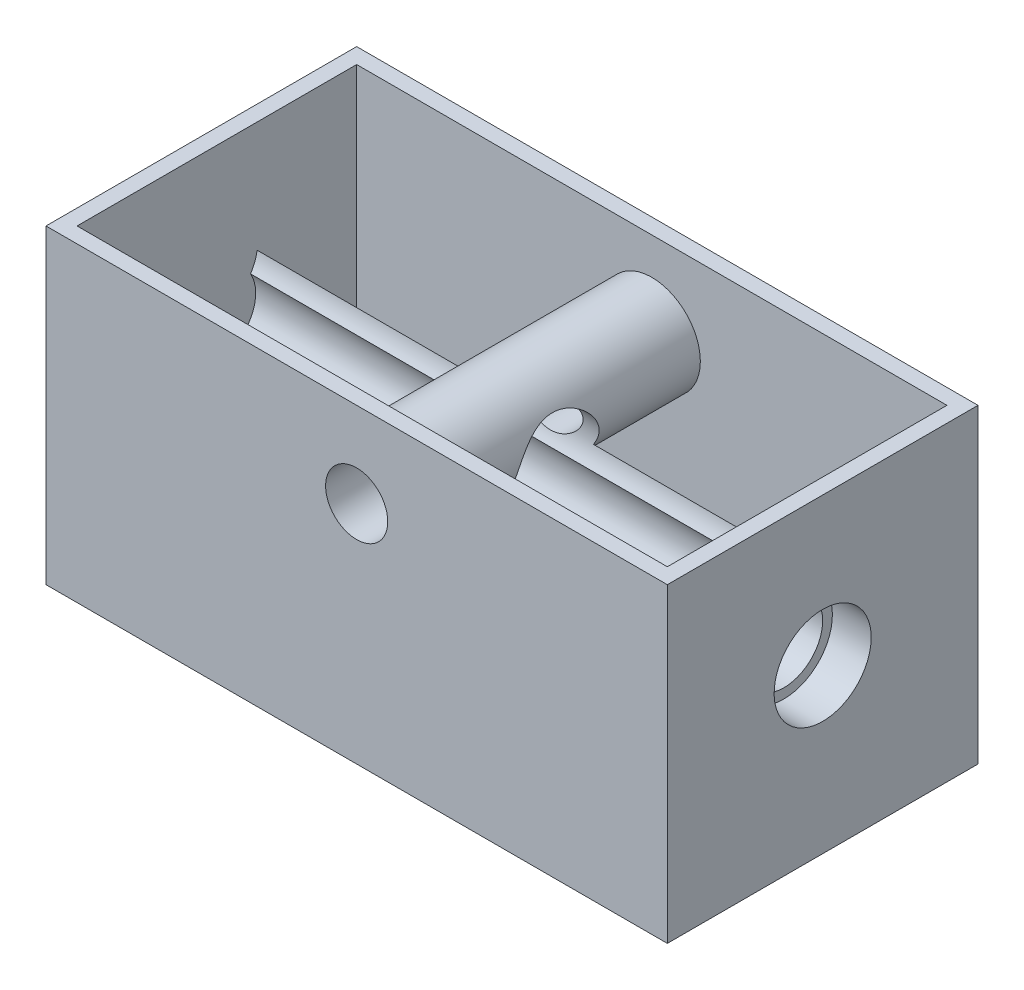
from build123d import *

# Parameters (mm, degrees)
SKETCH1_W           = 101.6
SKETCH1_H           = 50.8
BOSS_EXTRUDE1_DEPTH = 50.8
SKETCH2_R           = 7.9375
CUT_EXTRUDE1_DEPTH  = 6.35
SKETCH3_R           = 6.35
CUT_EXTRUDE2_DEPTH  = 102.6
SKETCH4_R           = 5.3975
CUT_EXTRUDE3_DEPTH  = 34.29
SHELL9_T            = -2.54
SKETCH5_R           = 7.022033088
CUT_EXTRUDE4_DEPTH  = 96.52
SKETCH7_R           = 7.9375
BOSS_EXTRUDE3_DEPTH = 11.43
SKETCH9_R           = 5.08
CUT_EXTRUDE5_DEPTH  = 34.29
SKETCH10_R          = 6.35
BOSS_EXTRUDE4_DEPTH = 2.54


with BuildPart() as part:
    # Sketch1 → Boss-Extrude1 (new body)
    with BuildSketch(Plane.XY):
        Rectangle(SKETCH1_W, SKETCH1_H)
    extrude(amount=-BOSS_EXTRUDE1_DEPTH)

    # Sketch2 → Cut-Extrude1 (cut)
    with BuildSketch(Plane(origin=(50.8, 0, 0), x_dir=(0, 0, -1), z_dir=(1, 0, 0))):
        with Locations((25.4, 1.27)):
            Circle(SKETCH2_R)
    extrude(amount=-CUT_EXTRUDE1_DEPTH, mode=Mode.SUBTRACT)

    # Sketch3 → Cut-Extrude2 (cut, through all)
    with BuildSketch(Plane(origin=(50.8, 0, 0), x_dir=(0, 0, -1), z_dir=(1, 0, 0))):
        with Locations((25.4, 1.27)):
            Circle(SKETCH3_R)
    extrude(amount=-CUT_EXTRUDE2_DEPTH, mode=Mode.SUBTRACT)

    # Sketch4 → Cut-Extrude3 (cut)
    with BuildSketch(Plane(origin=(0, 0, -50.8), x_dir=(-1, 0, 0), z_dir=(0, 0, -1))):
        with Locations((0, 11.461907579)):
            Circle(SKETCH4_R)
    extrude(amount=-CUT_EXTRUDE3_DEPTH, mode=Mode.SUBTRACT)

    # Shell9
    shell9_openings = [part.faces().sort_by_distance(p)[0] for p in [
        (0, 25.4, -25.4),
    ]]
    offset(amount=SHELL9_T, openings=shell9_openings, kind=Kind.INTERSECTION)

    # Sketch5 → Cut-Extrude4 (cut)
    with BuildSketch(Plane.ZY.offset(-48.26)):
        with Locations((-25.037035013, 8.282646085)):
            Circle(SKETCH5_R)
    extrude(amount=CUT_EXTRUDE4_DEPTH, mode=Mode.SUBTRACT)

    # Sketch7 → Boss-Extrude3 (add)
    with BuildSketch(Plane.XY.offset(-13.97)):
        with Locations((0, 11.461907579)):
            Circle(SKETCH7_R)
    extrude(amount=BOSS_EXTRUDE3_DEPTH)

    # Sketch9 → Cut-Extrude5 (cut)
    with BuildSketch(Plane.XY):
        with Locations((0, 11.461907579)):
            Circle(SKETCH9_R)
    extrude(amount=-CUT_EXTRUDE5_DEPTH, mode=Mode.SUBTRACT)

    # Sketch10 → Boss-Extrude4 (add)
    with BuildSketch(Plane.ZY.offset(50.8)):
        with Locations((-25.4, 1.27)):
            Circle(SKETCH10_R)
    extrude(amount=-BOSS_EXTRUDE4_DEPTH)


solid = part.part
